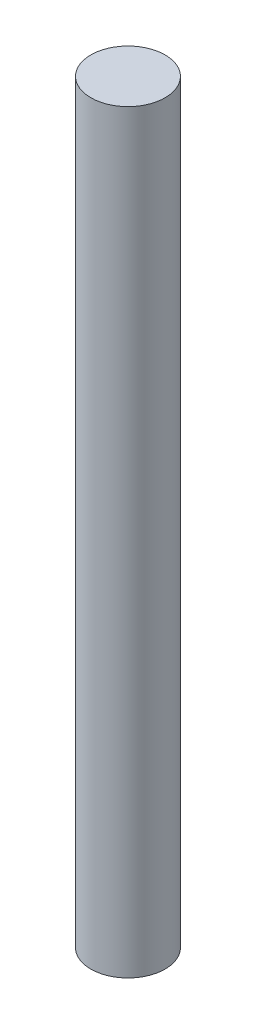
from build123d import *

# Parameters (mm, degrees)
SKETCH1_R           = 2.5
BOSS_EXTRUDE1_DEPTH = 50.8


with BuildPart() as part:
    # Sketch1 → Boss-Extrude1 (new body)
    with BuildSketch(Plane(origin=(0, 0, 0), x_dir=(1, 0, 0), z_dir=(0, 1, 0))):
        Circle(SKETCH1_R)
    extrude(amount=BOSS_EXTRUDE1_DEPTH)


solid = part.part
